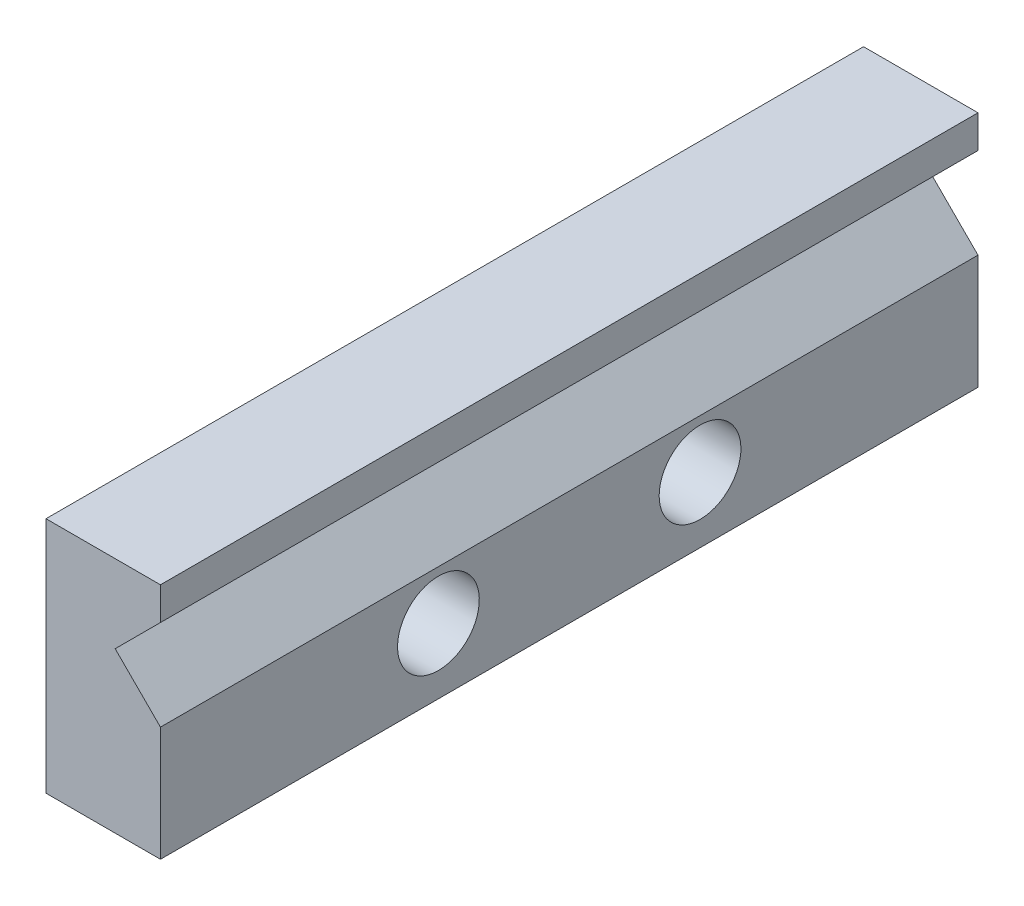
from build123d import *

# Parameters (mm, degrees)
BOSS_EXTRUDE1_DEPTH = 50
CUT_EXTRUDE1_REACH  = 9
SKETCH3_R           = 2.5


with BuildPart() as part:
    # Sketch2 → Boss-Extrude1 (new body)
    with BuildSketch(Plane.XY):
        Polygon((-15.713485752, 63.637116303), (-18.483485752, 60.867117128), (-15.713485752, 58.097116303), (-15.713485752, 51.097116303), (-22.713485752, 51.097116303), (-22.713485752, 65.637116303), (-15.713485752, 65.637116303), align=None)
    extrude(amount=BOSS_EXTRUDE1_DEPTH)

    # Sketch3 → Cut-Extrude1 (cut, up to next)
    with BuildSketch(Plane.ZY.offset(22.713485752), mode=Mode.PRIVATE) as cut_extrude1_sk1:
        with Locations((17, 55.097116303)):
            Circle(SKETCH3_R)
    cut_extrude1_tool1 = extrude(cut_extrude1_sk1.sketch, amount=-CUT_EXTRUDE1_REACH, mode=Mode.PRIVATE) & part.part
    add(cut_extrude1_tool1.solids().sort_by_distance((-22.713486, 55.097116, 17))[0], mode=Mode.SUBTRACT)
    # Sketch3 → Cut-Extrude1 (cut, up to next)
    with BuildSketch(Plane.ZY.offset(22.713485752), mode=Mode.PRIVATE) as cut_extrude1_sk2:
        with Locations((33, 55.097116303)):
            Circle(SKETCH3_R)
    cut_extrude1_tool2 = extrude(cut_extrude1_sk2.sketch, amount=-CUT_EXTRUDE1_REACH, mode=Mode.PRIVATE) & part.part
    add(cut_extrude1_tool2.solids().sort_by_distance((-22.713486, 55.097116, 33))[0], mode=Mode.SUBTRACT)


solid = part.part
